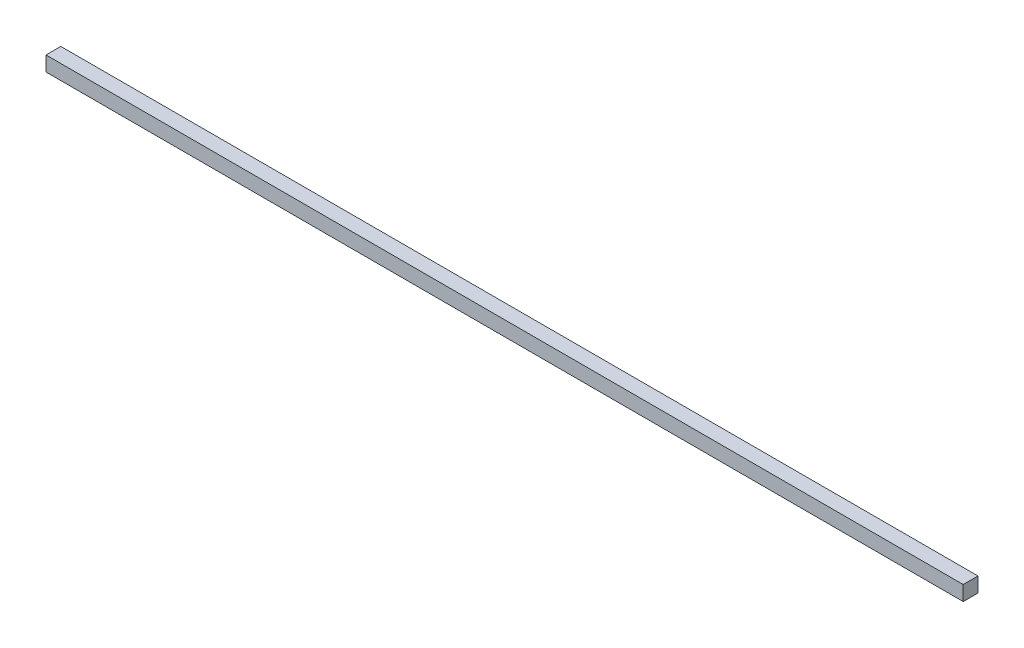
from build123d import *

# Parameters (mm, degrees)
SKETCH1_W           = 186
SKETCH1_H           = 3
BOSS_EXTRUDE1_DEPTH = 3


with BuildPart() as part:
    # Sketch1 → Boss-Extrude1 (new body)
    with BuildSketch(Plane(origin=(0, 0, 0), x_dir=(1, 0, 0), z_dir=(0, 1, 0))):
        with Locations((20.700424095, 82.591467185)):
            Rectangle(SKETCH1_W, SKETCH1_H)
    extrude(amount=BOSS_EXTRUDE1_DEPTH)


solid = part.part
